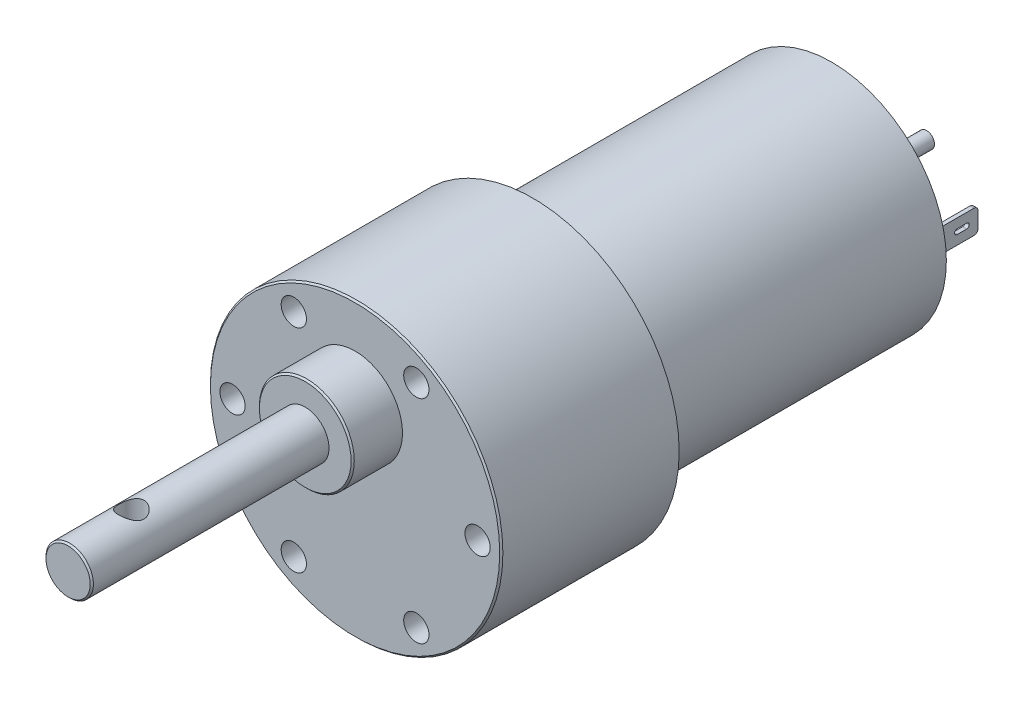
from build123d import *

# Parameters (mm, degrees)
SKETCH1_R               = 18.5
BOSS_EXTRUDE1_DEPTH     = 22.5
SKETCH2_R               = 1.6
CUT_EXTRUDE1_DEPTH      = 3.5
SKETCH3_R               = 3
BOSS_EXTRUDE2_DEPTH     = 36.3
SKETCH3_3_R             = 6
SKETCH3_3_R_2           = 3
BOSS_EXTRUDE3_DEPTH     = 6.3
SKETCH4_R               = 14.5
BOSS_EXTRUDE4_DEPTH     = 37.8
SKETCH5_R               = 5
BOSS_EXTRUDE5_DEPTH     = 3
SKETCH6_R               = 1
BOSS_EXTRUDE6_DEPTH     = 9
SKETCH7_W               = 0.5
SKETCH7_H               = 3
BOSS_EXTRUDE7_DEPTH     = 6.5
CUT_EXTRUDE2_DEPTH      = 0.5
FILLET1_R               = 0.5
CHAMFER1_SIZE           = 0.2
CUT_EXTRUDE3_DEPTH      = 67.7078706
CUT_EXTRUDE3_DEPTH_BACK = 67.7078706
SKETCH9_R               = 1.6
SCALE1_SCALE            = 0.6757


with BuildPart() as part:
    # Sketch1 → Boss-Extrude1 (new body)
    with BuildSketch(Plane.XY):
        Circle(SKETCH1_R)
    extrude(amount=BOSS_EXTRUDE1_DEPTH)

    # Sketch2 → Cut-Extrude1 (cut)
    with BuildSketch(Plane.XY.offset(22.5)):
        with Locations((-7.75, 13.423393759)):
            Circle(SKETCH2_R)
        with Locations((7.75, 13.423393759)):
            Circle(SKETCH2_R)
        with Locations((-15.5, 0)):
            Circle(SKETCH2_R)
        with Locations((-7.75, -13.423393759)):
            Circle(SKETCH2_R)
        with Locations((7.75, -13.423393759)):
            Circle(SKETCH2_R)
        with Locations((15.5, 0)):
            Circle(SKETCH2_R)
    extrude(amount=-CUT_EXTRUDE1_DEPTH, mode=Mode.SUBTRACT)

    # Sketch3 → Boss-Extrude2 (add)
    with BuildSketch(Plane.XY.offset(22.5)):
        with Locations((0, 7)):
            Circle(SKETCH3_R)
    extrude(amount=BOSS_EXTRUDE2_DEPTH)

    # Sketch3_3 → Boss-Extrude3 (add)
    with BuildSketch(Plane.XY.offset(22.5)):
        with Locations((0, 7)):
            Circle(SKETCH3_3_R)
        with Locations((0, 7)):
            Circle(SKETCH3_3_R_2, mode=Mode.SUBTRACT)
    extrude(amount=BOSS_EXTRUDE3_DEPTH)

    # Sketch4 → Boss-Extrude4 (add)
    with BuildSketch(Plane(origin=(0, 0, 0), x_dir=(-1, 0, 0), z_dir=(0, 0, -1))):
        Circle(SKETCH4_R)
    extrude(amount=BOSS_EXTRUDE4_DEPTH)

    # Sketch5 → Boss-Extrude5 (add)
    with BuildSketch(Plane(origin=(0, 0, -37.8), x_dir=(-1, 0, 0), z_dir=(0, 0, -1))):
        Circle(SKETCH5_R)
    extrude(amount=BOSS_EXTRUDE5_DEPTH)

    # Sketch6 → Boss-Extrude6 (add)
    with BuildSketch(Plane(origin=(0, 0, -40.8), x_dir=(-1, 0, 0), z_dir=(0, 0, -1))):
        Circle(SKETCH6_R)
    extrude(amount=BOSS_EXTRUDE6_DEPTH)

    # Sketch7 → Boss-Extrude7 (add)
    with BuildSketch(Plane(origin=(0, 0, -37.8), x_dir=(-1, 0, 0), z_dir=(0, 0, -1))):
        with Locations((-11.75, 0)):
            Rectangle(SKETCH7_W, SKETCH7_H)
        with Locations((11.75, 0)):
            Rectangle(SKETCH7_W, SKETCH7_H)
    extrude(amount=BOSS_EXTRUDE7_DEPTH)

    # Sketch8 → Cut-Extrude2 (cut)
    with BuildSketch(Plane(origin=(12, 0, 0), x_dir=(0, 0, -1), z_dir=(1, 0, 0))):
        with BuildLine():
            Line((42.865122037, -0.320114275), (41.665122037, -0.320114275))
            ThreePointArc((41.665122037, -0.320114275), (41.345007763, 0), (41.665122037, 0.320114275))
            Line((41.665122037, 0.320114275), (42.865122037, 0.320114275))
            ThreePointArc((42.865122037, 0.320114275), (43.185236312, 0), (42.865122037, -0.320114275))
        make_face()
    cut_extrude2 = extrude(amount=-CUT_EXTRUDE2_DEPTH, mode=Mode.SUBTRACT)

    # Mirror2: Cut-Extrude2 across plane
    add(cut_extrude2.mirror(Plane(origin=(0, 0, 0), x_dir=(0, 0, 1), z_dir=(1, 0, 0))), mode=Mode.SUBTRACT)

    # Fillet1
    fillet1_edges = [part.edges().sort_by_distance(p)[0] for p in [
        (-11.75, 1.5, -44.3),
        (-11.75, -1.5, -44.3),
        (11.75, 1.5, -44.3),
        (11.75, -1.5, -44.3),
    ]]
    fillet(fillet1_edges, radius=FILLET1_R)

    # Chamfer1
    chamfer1_edges = [part.edges().sort_by_distance(p)[0] for p in [
        (-18.5, 0, 22.5),
        (-6, 7, 28.8),
        (-3, 7, 58.8),
    ]]
    chamfer(chamfer1_edges, length=CHAMFER1_SIZE)

    # Sketch9 → Cut-Extrude3 (cut, two sides: drawn at the far end of the back side and taken through both)
    with BuildSketch(Plane(origin=(0, 7, 0), x_dir=(1, 0, 0), z_dir=(0, 1, 0)).offset(-CUT_EXTRUDE3_DEPTH_BACK)):
        with Locations((0, -50.8)):
            Circle(SKETCH9_R)
    extrude(amount=CUT_EXTRUDE3_DEPTH + CUT_EXTRUDE3_DEPTH_BACK, mode=Mode.SUBTRACT)


with BuildPart() as part_1:
    # Scale1: scaled about (3.1e-08, 0.208571854, -3.181081733)
    add(part.part.scale(SCALE1_SCALE).moved(Location((1e-08, 0.067639852, -1.031624806))))


solid = part_1.part
